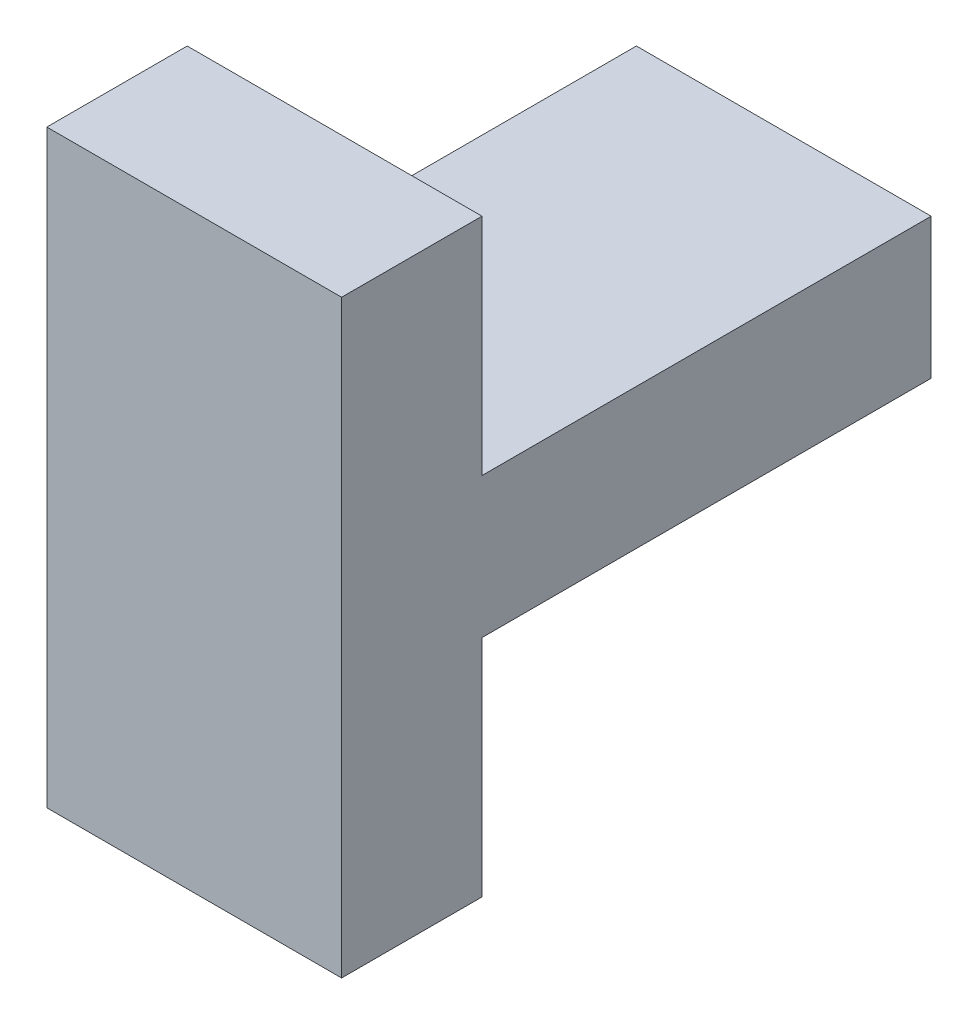
from build123d import *

# Parameters (mm, degrees)
BOSS_EXTRUDE1_DEPTH = 21


with BuildPart() as part:
    # Sketch1 → Boss-Extrude1 (new body)
    with BuildSketch(Plane.YZ):
        Polygon((0, 0), (10, 0), (10, 32), (26, 32), (26, 42), (-16, 42), (-16, 32), (0, 32), align=None)
    extrude(amount=BOSS_EXTRUDE1_DEPTH)


solid = part.part
